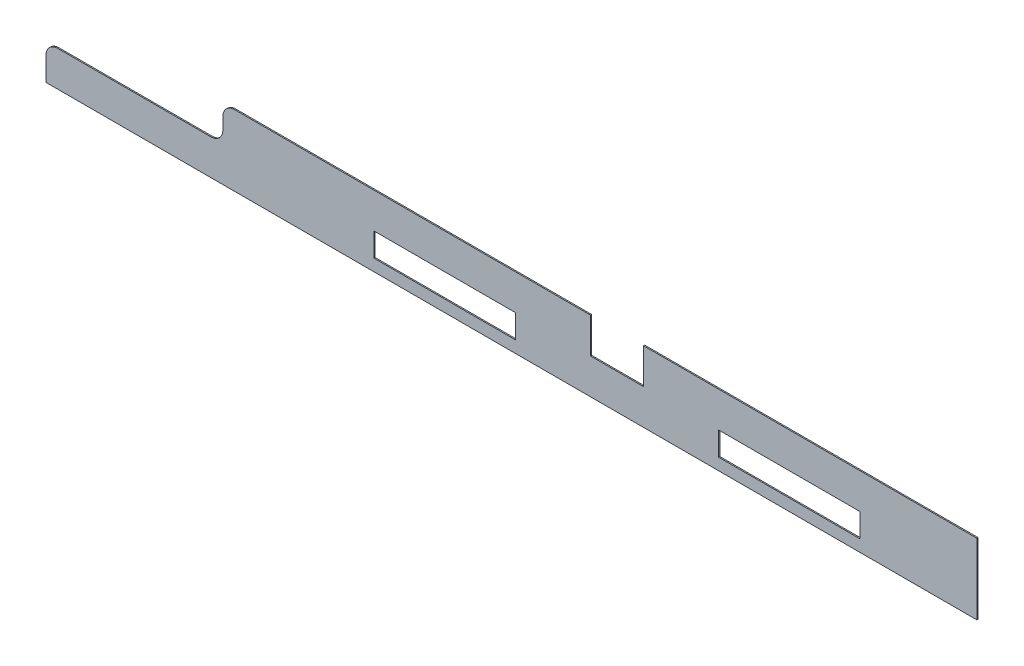
from build123d import *

# Parameters (mm, degrees)
ESQUISSE1_W        = 240
ESQUISSE1_H        = 40
BOSS_EXTRU_1_DEPTH = 2
CONG_1_R           = 20


with BuildPart() as part:
    # Esquisse1 → Boss.-Extru.1 (new body)
    with BuildSketch(Plane.XY):
        Polygon((-610.5, 0), (610.5, 0), (610.5, 120), (45, 120), (45, 60), (-45, 60), (-45, 120), (-610.5, 120), (-668.615113653, 120), (-668.615113653, 60), (-968.615113653, 60), (-968.615113653, 0), align=None)
        with Locations((292.5, 40)):
            Rectangle(ESQUISSE1_W, ESQUISSE1_H, mode=Mode.SUBTRACT)
        with Locations((-292.5, 40)):
            Rectangle(ESQUISSE1_W, ESQUISSE1_H, mode=Mode.SUBTRACT)
    extrude(amount=BOSS_EXTRU_1_DEPTH)

    # Congé1
    cong_1_edges = [part.edges().sort_by_distance(p)[0] for p in [
        (-968.615113653, 60, 1),
        (-668.615113653, 60, 1),
        (-668.615113653, 120, 1),
    ]]
    fillet(cong_1_edges, radius=CONG_1_R)


solid = part.part
